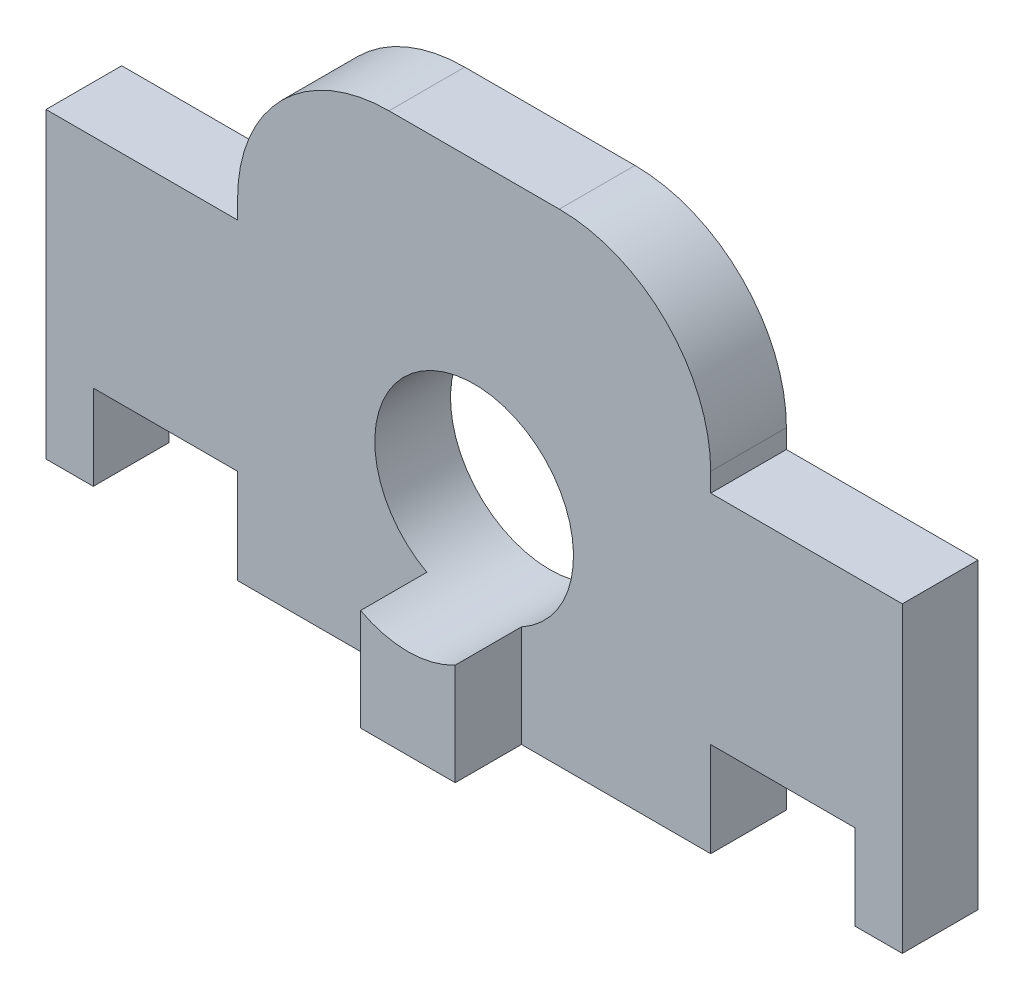
from build123d import *

# Parameters (mm, degrees)
BOSS_EXTRUDE1_DEPTH = 15
SKETCH3_W           = 10
SKETCH3_H           = 10
CUT_EXTRUDE1_DEPTH  = 54.949798285
CUT_EXTRUDE2_DEPTH  = 7
SKETCH5_W           = 5.25
SKETCH5_H           = 8
BOSS_EXTRUDE2_DEPTH = 23
SKETCH5_3_W         = 5
SKETCH5_3_H         = 8
BOSS_EXTRUDE3_DEPTH = 32
SKETCH5_5_W         = 5
SKETCH5_5_H         = 8
BOSS_EXTRUDE4_DEPTH = 32
SKETCH5_6_W         = 5.25
SKETCH5_6_H         = 8
BOSS_EXTRUDE5_DEPTH = 23


with BuildPart() as part:
    # Sketch2 → Boss-Extrude1 (new body)
    with BuildSketch(Plane.XY):
        Polygon((36.074313409, 13.794830372), (-33.925686591, 13.794830372), (-33.925686591, -37.205169628), (1.074313409, -37.205169628), (36.074313409, -37.205169628), align=None)
        with BuildLine():
            ThreePointArc((11.574313409, -17.205169628), (8.498934611, -24.629790831), (1.074313409, -27.705169628))
            ThreePointArc((1.074313409, -27.705169628), (-6.350307794, -9.780548426), (11.574313409, -17.205169628))
        make_face(mode=Mode.SUBTRACT)
    extrude(amount=BOSS_EXTRUDE1_DEPTH)

    # Sketch3 → Cut-Extrude1 (cut, through all)
    with BuildSketch(Plane.XY.offset(15)):
        with Locations((31.074313409, -32.205169628)):
            Rectangle(SKETCH3_W, SKETCH3_H)
        with Locations((-28.925686591, -32.205169628)):
            Rectangle(SKETCH3_W, SKETCH3_H)
        with BuildLine():
            ThreePointArc((-23.925686591, -2.205169628), (-19.23939509, 9.108538871), (-7.925686591, 13.794830372))
            Line((-7.925686591, 13.794830372), (-33.925686591, 13.794830372))
            Line((-33.925686591, 13.794830372), (-33.925686591, -4.205169628))
            Line((-33.925686591, -4.205169628), (-23.925686591, -4.205169628))
            Line((-23.925686591, -4.205169628), (-23.925686591, -2.205169628))
        make_face()
        with BuildLine():
            Line((26.074313409, -4.205169628), (36.074313409, -4.205169628))
            Line((36.074313409, -4.205169628), (36.074313409, 13.794830372))
            Line((36.074313409, 13.794830372), (10.074313409, 13.794830372))
            ThreePointArc((10.074313409, 13.794830372), (21.388021908, 9.108538871), (26.074313409, -2.205169628))
            Line((26.074313409, -2.205169628), (26.074313409, -4.205169628))
        make_face()
    extrude(amount=-CUT_EXTRUDE1_DEPTH, mode=Mode.SUBTRACT)

    # Sketch4 → Cut-Extrude2 (cut)
    with BuildSketch(Plane.XY.offset(15)):
        with BuildLine():
            Line((-3.925686591, -37.205169628), (-3.925686591, -26.438262285))
            ThreePointArc((-3.925686591, -26.438262285), (-4.299232906, -8.184360352), (11.574313409, -17.205169628))
            ThreePointArc((11.574313409, -17.205169628), (10.095122685, -22.578715943), (6.074313409, -26.438262285))
            Line((6.074313409, -26.438262285), (6.074313409, -37.205169628))
            Line((6.074313409, -37.205169628), (26.074313409, -37.205169628))
            Line((26.074313409, -37.205169628), (26.074313409, -27.205169628))
            Line((26.074313409, -27.205169628), (36.074313409, -27.205169628))
            Line((36.074313409, -27.205169628), (36.074313409, -4.205169628))
            Line((36.074313409, -4.205169628), (26.074313409, -4.205169628))
            Line((26.074313409, -4.205169628), (26.074313409, -2.205169628))
            ThreePointArc((26.074313409, -2.205169628), (21.388021908, 9.108538871), (10.074313409, 13.794830372))
            Line((10.074313409, 13.794830372), (-7.925686591, 13.794830372))
            ThreePointArc((-7.925686591, 13.794830372), (-19.23939509, 9.108538871), (-23.925686591, -2.205169628))
            Line((-23.925686591, -2.205169628), (-23.925686591, -4.205169628))
            Line((-23.925686591, -4.205169628), (-33.925686591, -4.205169628))
            Line((-33.925686591, -4.205169628), (-33.925686591, -27.205169628))
            Line((-33.925686591, -27.205169628), (-23.925686591, -27.205169628))
            Line((-23.925686591, -27.205169628), (-23.925686591, -37.205169628))
            Line((-23.925686591, -37.205169628), (-3.925686591, -37.205169628))
        make_face()
    extrude(amount=-CUT_EXTRUDE2_DEPTH, mode=Mode.SUBTRACT)

    # Sketch5 → Boss-Extrude2 (add)
    with BuildSketch(Plane(origin=(0, -4.205169628, 0), x_dir=(1, 0, 0), z_dir=(0, 1, 0))):
        with Locations((-36.550686591, -4)):
            Rectangle(SKETCH5_W, SKETCH5_H)
    extrude(amount=-BOSS_EXTRUDE2_DEPTH)

    # Sketch5_3 → Boss-Extrude3 (add)
    with BuildSketch(Plane(origin=(0, -4.205169628, 0), x_dir=(1, 0, 0), z_dir=(0, 1, 0))):
        with Locations((-41.675686591, -4)):
            Rectangle(SKETCH5_3_W, SKETCH5_3_H)
    extrude(amount=-BOSS_EXTRUDE3_DEPTH)



with BuildPart() as body_2:
    # Sketch5_5 → Boss-Extrude4 (new body)
    with BuildSketch(Plane(origin=(0, -4.205169628, 0), x_dir=(1, 0, 0), z_dir=(0, 1, 0))):
        with Locations((43.824313409, -4)):
            Rectangle(SKETCH5_5_W, SKETCH5_5_H)
    extrude(amount=-BOSS_EXTRUDE4_DEPTH)


with BuildPart() as part_1:
    add(part.part)

    add(body_2.part)  # Boss-Extrude5 merges body 2
    # Sketch5_6 → Boss-Extrude5 (add)
    with BuildSketch(Plane(origin=(0, -4.205169628, 0), x_dir=(1, 0, 0), z_dir=(0, 1, 0))):
        with Locations((38.699313409, -4)):
            Rectangle(SKETCH5_6_W, SKETCH5_6_H)
    extrude(amount=-BOSS_EXTRUDE5_DEPTH)


solid = part_1.part
